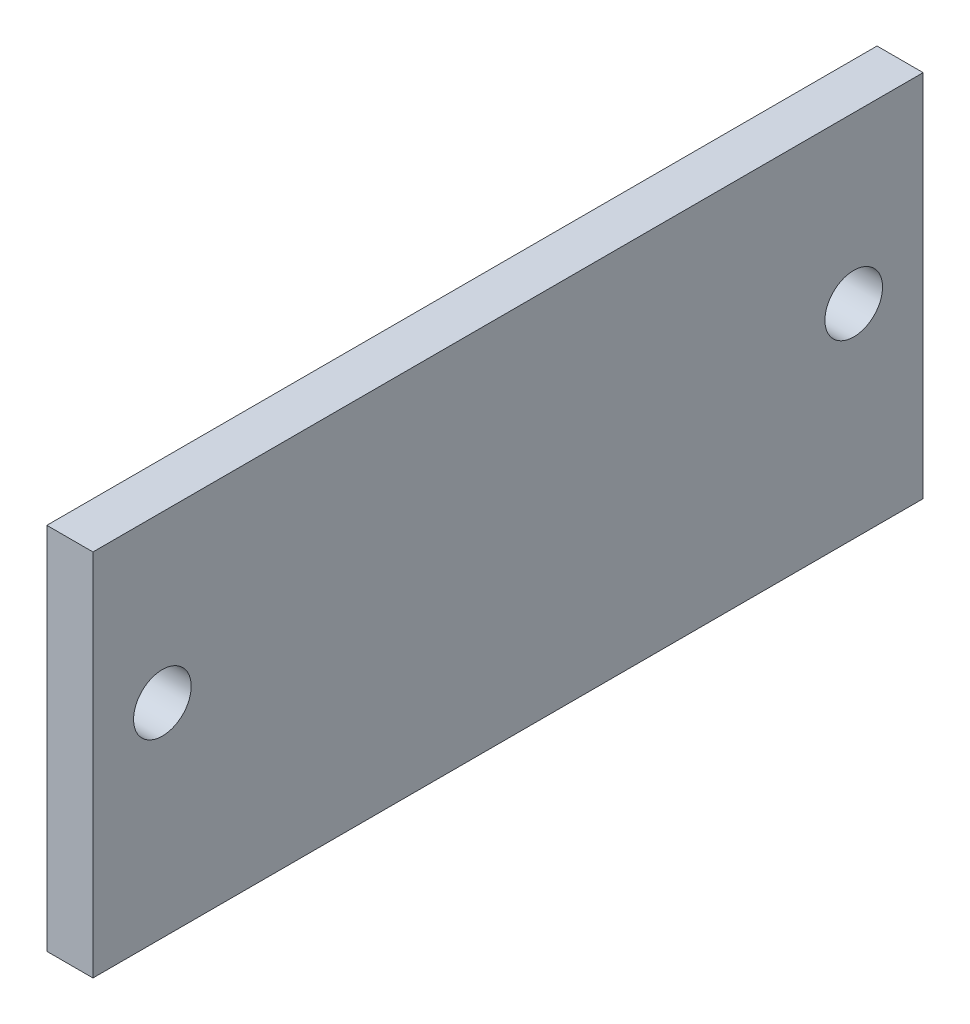
from build123d import *

# Parameters (mm, degrees)
SKETCH1_W           = 228.6
SKETCH1_H           = 101.6
BOSS_EXTRUDE1_DEPTH = 12.7
SKETCH2_R           = 7.9375
CUT_EXTRUDE1_DEPTH  = 12.7


with BuildPart() as part:
    # Sketch1 → Boss-Extrude1 (new body)
    with BuildSketch(Plane(origin=(0, 0, 0), x_dir=(0, 0, -1), z_dir=(1, 0, 0))):
        Rectangle(SKETCH1_W, SKETCH1_H)
    extrude(amount=-BOSS_EXTRUDE1_DEPTH)

    # Sketch2 → Cut-Extrude1 (cut)
    with BuildSketch(Plane(origin=(0, 0, 0), x_dir=(0, 0, -1), z_dir=(1, 0, 0))):
        with Locations((-95.1865, 5.2705)):
            Circle(SKETCH2_R)
    cut_extrude1 = extrude(amount=-CUT_EXTRUDE1_DEPTH, mode=Mode.SUBTRACT)

    # Mirror1: Cut-Extrude1 across plane
    add(cut_extrude1.mirror(Plane.XY), mode=Mode.SUBTRACT)


solid = part.part
